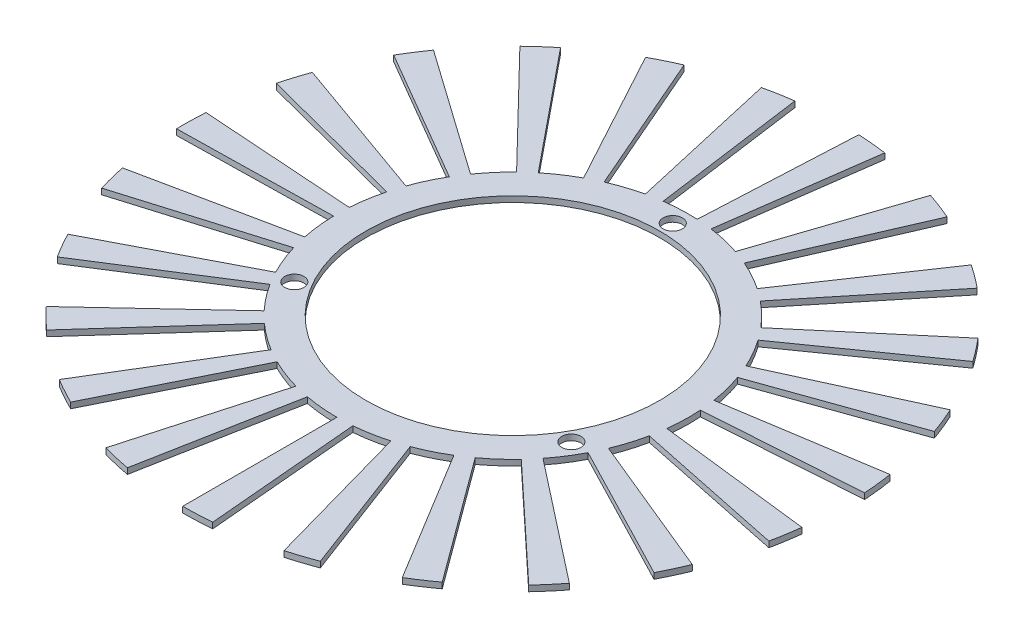
from build123d import *

# Parameters (mm, degrees)
SKETCH1_R           = 30.25
SKETCH1_R_2         = 25.25
EXTRUDE_THIN1_DEPTH = 1
SKETCH2_R           = 1.65
CUT_EXTRUDE3_DEPTH  = 10
BOSS_EXTRUDE1_DEPTH = 1


with BuildPart() as part:
    # Sketch1 → Extrude-Thin1 (new body)
    with BuildSketch(Plane(origin=(0, 0, 0), x_dir=(1, 0, 0), z_dir=(0, 1, 0))):
        Circle(SKETCH1_R)
        Circle(SKETCH1_R_2, mode=Mode.SUBTRACT)
    extrude(amount=-EXTRUDE_THIN1_DEPTH)

    # Sketch2 → Cut-Extrude3 (cut)
    with BuildSketch(Plane(origin=(0, 0, 0), x_dir=(1, 0, 0), z_dir=(0, 1, 0))):
        with Locations((0, 27.5)):
            Circle(SKETCH2_R)
        with Locations((23.815698604, -13.75)):
            Circle(SKETCH2_R)
        with Locations((-23.815698604, -13.75)):
            Circle(SKETCH2_R)
    extrude(amount=-CUT_EXTRUDE3_DEPTH, mode=Mode.SUBTRACT)

    # Sketch5 → Boss-Extrude1 (add)
    with BuildSketch(Plane.XZ.offset(1)):
        with BuildLine():
            Line((0, 56.75), (0, 30.25))
            ThreePointArc((0, 30.25), (1.319486468, 30.221208703), (2.636461218, 30.134889617))
            Line((2.636461218, 30.134889617), (4.946088401, 56.534049117))
            ThreePointArc((4.946088401, 56.534049117), (2.475400233, 56.695986575), (0, 56.75))
        make_face()
        with BuildLine():
            Line((15.310966763, 54.645556057), (8.161352328, 29.128247942))
            ThreePointArc((8.161352328, 29.128247942), (9.424140859, 28.744531116), (10.668990002, 28.306097441))
            Line((10.668990002, 28.306097441), (20.015377938, 53.103174538))
            ThreePointArc((20.015377938, 53.103174538), (17.679999793, 53.925690606), (15.310966763, 54.645556057))
        make_face()
        with BuildLine():
            Line((29.486389165, 48.488301208), (15.717414489, 25.846186988))
            ThreePointArc((15.717414489, 25.846186988), (16.829849835, 25.136003154), (17.910248605, 24.377971509))
            Line((17.910248605, 24.377971509), (33.600218458, 45.733880434))
            ThreePointArc((33.600218458, 45.733880434), (31.573354649, 47.155972858), (29.486389165, 48.488301208))
        make_face()
        with BuildLine():
            Line((41.474940973, 38.734890878), (22.107787919, 20.647232582))
            ThreePointArc((22.107787919, 20.647232582), (22.98736584, 19.663252827), (23.823186003, 18.641842952))
            Line((23.823186003, 18.641842952), (44.693084485, 34.972713638))
            ThreePointArc((44.693084485, 34.972713638), (43.125058229, 36.888912328), (41.474940973, 38.734890878))
        make_face()
        with BuildLine():
            Line((50.387486144, 26.108690891), (26.858527857, 13.916967391))
            ThreePointArc((26.858527857, 13.916967391), (27.440014081, 12.732168992), (27.969266679, 11.523134184))
            Line((27.969266679, 11.523134184), (52.471268894, 21.61778066))
            ThreePointArc((52.471268894, 21.61778066), (51.478373524, 23.885969926), (50.387486144, 26.108690891))
        make_face()
        with BuildLine():
            Line((55.563021976, 11.546128741), (29.617293652, 6.154544395))
            ThreePointArc((29.617293652, 6.154544395), (29.857562008, 4.856798428), (30.040994796, 3.549807269))
            Line((30.040994796, 3.549807269), (56.357899329, 6.659555785))
            ThreePointArc((56.357899329, 6.659555785), (56.013773353, 9.111514406), (55.563021976, 11.546128741))
        make_face()
        with BuildLine():
            Line((56.617702652, -3.872756958), (30.179480268, -2.064333004))
            ThreePointArc((30.179480268, -2.064333004), (30.060711149, -3.378778657), (29.884719758, -4.686792612))
            Line((29.884719758, -4.686792612), (56.06472219, -8.792577876))
            ThreePointArc((56.06472219, -8.792577876), (56.394887858, -6.338700456), (56.617702652, -3.872756958))
        make_face()
        with BuildLine():
            Line((53.47330733, -19.004417991), (28.503392894, -10.130108268))
            ThreePointArc((28.503392894, -10.130108268), (28.034394863, -11.363767186), (27.512031768, -12.575794526))
            Line((27.512031768, -12.575794526), (51.613481086, -23.59260626))
            ThreePointArc((51.613481086, -23.59260626), (52.59345152, -21.318802902), (53.47330733, -19.004417991))
        make_face()
        with BuildLine():
            Line((46.363041428, -32.72660828), (24.713339264, -17.444579744))
            ThreePointArc((24.713339264, -17.444579744), (23.928895759, -18.505957088), (23.098902242, -19.532107291))
            Line((23.098902242, -19.532107291), (43.334304206, -36.642878967))
            ThreePointArc((43.334304206, -36.642878967), (44.891399482, -34.717787264), (46.363041428, -32.72660828))
        make_face()
        with BuildLine():
            Line((35.814240841, -44.021615747), (19.090410316, -23.465266544))
            ThreePointArc((19.090410316, -23.465266544), (18.048699924, -24.275644812), (16.972632807, -25.039813011))
            Line((16.972632807, -25.039813011), (31.841220224, -46.97551697))
            ThreePointArc((31.841220224, -46.97551697), (33.859957709, -45.541912168), (35.814240841, -44.021615747))
        make_face()
        with BuildLine():
            Line((22.609261849, -52.05174136), (12.051632968, -27.745641871))
            ThreePointArc((12.051632968, -27.745641871), (10.829914583, -28.244919014), (9.587580841, -28.690430349))
            Line((9.587580841, -28.690430349), (17.986618602, -53.824195779))
            ThreePointArc((17.986618602, -53.824195779), (20.317277772, -52.988401787), (22.609261849, -52.05174136))
        make_face()
        with BuildLine():
            Line((7.727457336, -56.221427438), (4.119041135, -29.968249868))
            ThreePointArc((4.119041135, -29.968249868), (2.807924021, -30.119396785), (1.491461864, -30.213209719))
            Line((1.491461864, -30.213209719), (2.798031761, -56.680980216))
            ThreePointArc((2.798031761, -56.680980216), (5.267758287, -56.504984051), (7.727457336, -56.221427438))
        make_face()
        with BuildLine():
            Line((-7.727457336, -56.221427438), (-4.119041135, -29.968249868))
            ThreePointArc((-4.119041135, -29.968249868), (-5.42231742, -29.760056683), (-6.715272016, -29.49521354))
            Line((-6.715272016, -29.49521354), (-12.598072295, -55.333995649))
            ThreePointArc((-12.598072295, -55.333995649), (-10.172446731, -55.830850141), (-7.727457336, -56.221427438))
        make_face()
        with BuildLine():
            Line((-22.609261849, -52.05174136), (-12.051632968, -27.745641871))
            ThreePointArc((-12.051632968, -27.745641871), (-13.250410384, -27.193549321), (-14.423964891, -26.589692304))
            Line((-14.423964891, -26.589692304), (-27.059834961, -49.88314176))
            ThreePointArc((-27.059834961, -49.88314176), (-24.858207911, -51.015997486), (-22.609261849, -52.05174136))
        make_face()
        with BuildLine():
            Line((-35.814240841, -44.021615747), (-19.090410316, -23.465266544))
            ThreePointArc((-19.090410316, -23.465266544), (-20.095781026, -22.610220807), (-21.062898275, -21.71213523))
            Line((-21.062898275, -21.71213523), (-39.514693459, -40.732683448))
            ThreePointArc((-39.514693459, -40.732683448), (-37.700349529, -42.417521679), (-35.814240841, -44.021615747))
        make_face()
        with BuildLine():
            Line((-46.363041428, -32.72660828), (-24.713339264, -17.444579744))
            ThreePointArc((-24.713339264, -17.444579744), (-25.450739522, -16.349995651), (-26.139692851, -15.224288412))
            Line((-26.139692851, -15.224288412), (-49.038927911, -28.561268343))
            ThreePointArc((-49.038927911, -28.561268343), (-47.74642869, -30.673132337), (-46.363041428, -32.72660828))
        make_face()
        with BuildLine():
            Line((-53.47330733, -19.004417991), (-28.503392894, -10.130108268))
            ThreePointArc((-28.503392894, -10.130108268), (-28.918133096, -8.877166114), (-29.277825989, -7.607325769))
            Line((-29.277825989, -7.607325769), (-54.926169417, -14.271594625))
            ThreePointArc((-54.926169417, -14.271594625), (-54.25137366, -16.65385709), (-53.47330733, -19.004417991))
        make_face()
        with BuildLine():
            Line((-56.617702652, -3.872756958), (-30.179480268, -2.064333004))
            ThreePointArc((-30.179480268, -2.064333004), (-30.240801031, -0.745957776), (-30.24455671, 0.573837425))
            Line((-30.24455671, 0.573837425), (-56.739788209, 1.076537978))
            ThreePointArc((-56.739788209, 1.076537978), (-56.73274243, -1.399441448), (-56.617702652, -3.872756958))
        make_face()
        with BuildLine():
            Line((-55.563021976, 11.546128741), (-29.617293652, 6.154544395))
            ThreePointArc((-29.617293652, 6.154544395), (-29.320647095, 7.440574837), (-28.96818702, 8.712441722))
            Line((-28.96818702, 8.712441722), (-54.345276476, 16.344828685))
            ThreePointArc((-54.345276476, 16.344828685), (-55.006503229, 13.958764363), (-55.563021976, 11.546128741))
        make_face()
        with BuildLine():
            Line((-50.387486144, 26.108690891), (-26.858527857, 13.916967391))
            ThreePointArc((-26.858527857, 13.916967391), (-26.225914898, 15.075274053), (-25.54337942, 16.204884073))
            Line((-25.54337942, 16.204884073), (-47.9202242, 30.40089822))
            ThreePointArc((-47.9202242, 30.40089822), (-49.200683321, 28.281712479), (-50.387486144, 26.108690891))
        make_face()
        with BuildLine():
            Line((-41.474940973, 38.734890878), (-22.107787919, 20.647232582))
            ThreePointArc((-22.107787919, 20.647232582), (-21.186126568, 21.591909157), (-20.22413622, 22.495484305))
            Line((-20.22413622, 22.495484305), (-37.941148116, 42.202272209))
            ThreePointArc((-37.941148116, 42.202272209), (-39.745873809, 40.507135361), (-41.474940973, 38.734890878))
        make_face()
        with BuildLine():
            Line((-29.486389165, 48.488301208), (-15.717414489, 25.846186988))
            ThreePointArc((-15.717414489, 25.846186988), (-14.575060151, 26.507171136), (-13.404961357, 27.117697377))
            Line((-13.404961357, 27.117697377), (-25.148150645, 50.873696731))
            ThreePointArc((-25.148150645, 50.873696731), (-27.343294663, 49.72832932), (-29.486389165, 48.488301208))
        make_face()
        with BuildLine():
            Line((-15.310966763, 54.645556057), (-8.161352327, 29.128247942))
            ThreePointArc((-8.161352327, 29.128247942), (-6.883028198, 29.456517493), (-5.591601834, 29.728714889))
            Line((-5.591601834, 29.728714889), (-10.490029886, 55.772051899))
            ThreePointArc((-10.490029886, 55.772051899), (-12.912788438, 55.261400586), (-15.310966763, 54.645556057))
        make_face()
    extrude(amount=-BOSS_EXTRUDE1_DEPTH)


solid = part.part
